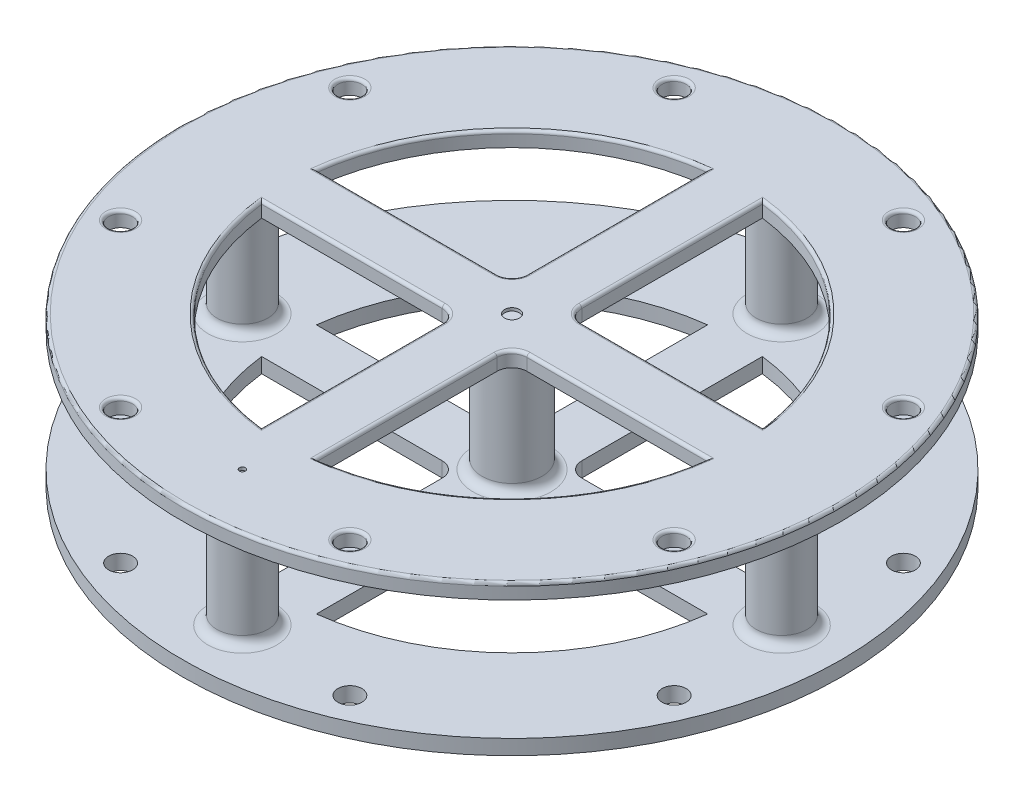
from build123d import *

# Parameters (mm, degrees)
SKETCH1_R               = 279.4
SKETCH1_R_2             = 10.16
SKETCH1_R_3             = 228.6
BOSS_EXTRUDE1_DEPTH     = 127
FILLET1_R               = 2.54
SKETCH2_W               = 558.8
SKETCH2_H               = 101.6
CUT_EXTRUDE1_DEPTH      = 416.039419845
CUT_EXTRUDE1_DEPTH_BACK = 416.039419845
SKETCH3_R               = 6.35
CUT_EXTRUDE2_DEPTH      = 6.35
SKETCH5_R               = 3.175
BOSS_EXTRUDE3_DEPTH     = 2.54
BOSS_EXTRUDE4_REACH     = 414.044
SKETCH6_R               = 25.4
SKETCH6_R_2             = 21.59
FILLET2_R               = 7.62
FILLET3_R               = 7.62
SKETCH7_R               = 6.35
SKETCH7_R_2             = 2.54
CUT_EXTRUDE3_DEPTH      = 2.54


with BuildPart() as part:
    # Sketch1 → Boss-Extrude1 (new body)
    with BuildSketch(Plane(origin=(0, 0, 0), x_dir=(1, 0, 0), z_dir=(0, 1, 0))):
        with Locations(Location((0, 0, 0), (0, 0, 270))):
            Circle(SKETCH1_R)
        with Locations(Location((234.665401258, -97.201591821, 0), (0, 0, 270))):
            Circle(SKETCH1_R_2, mode=Mode.SUBTRACT)
        with Locations(Location((97.201591821, -234.665401258, 0), (0, 0, 270))):
            Circle(SKETCH1_R_2, mode=Mode.SUBTRACT)
        with Locations(Location((97.201591821, 234.665401258, 0), (0, 0, 270))):
            Circle(SKETCH1_R_2, mode=Mode.SUBTRACT)
        with Locations(Location((234.665401258, 97.201591821, 0), (0, 0, 270))):
            Circle(SKETCH1_R_2, mode=Mode.SUBTRACT)
        with Locations(Location((-234.665401258, 97.201591821, 0), (0, 0, 270))):
            Circle(SKETCH1_R_2, mode=Mode.SUBTRACT)
        with Locations(Location((-97.201591821, 234.665401258, 0), (0, 0, 270))):
            Circle(SKETCH1_R_2, mode=Mode.SUBTRACT)
        with Locations(Location((-97.201591821, -234.665401258, 0), (0, 0, 270))):
            Circle(SKETCH1_R_2, mode=Mode.SUBTRACT)
        with Locations(Location((-234.665401258, -97.201591821, 0), (0, 0, 270))):
            Circle(SKETCH1_R_2, mode=Mode.SUBTRACT)
        Circle(SKETCH1_R_3, mode=Mode.SUBTRACT)
        Circle(SKETCH1_R_3)
        with BuildLine():
            ThreePointArc((-23.221024484, 189.07943839), (-134.703841816, 134.703841816), (-189.07943839, 23.221024484))
            Line((-189.07943839, 23.221024484), (-35.921024484, 23.221024484))
            ThreePointArc((-35.921024484, 23.221024484), (-26.940768363, 26.940768363), (-23.221024484, 35.921024484))
            Line((-23.221024484, 35.921024484), (-23.221024484, 189.07943839))
        make_face(mode=Mode.SUBTRACT)
        with BuildLine():
            ThreePointArc((189.07943839, 23.221024484), (134.703841816, 134.703841816), (23.221024484, 189.07943839))
            Line((23.221024484, 189.07943839), (23.221024484, 35.921024484))
            ThreePointArc((23.221024484, 35.921024484), (26.940768363, 26.940768363), (35.921024484, 23.221024484))
            Line((35.921024484, 23.221024484), (189.07943839, 23.221024484))
        make_face(mode=Mode.SUBTRACT)
        with BuildLine():
            ThreePointArc((-189.07943839, -23.221024484), (-134.703841816, -134.703841816), (-23.221024484, -189.07943839))
            Line((-23.221024484, -189.07943839), (-23.221024484, -35.921024484))
            ThreePointArc((-23.221024484, -35.921024484), (-26.940768363, -26.940768363), (-35.921024484, -23.221024484))
            Line((-35.921024484, -23.221024484), (-189.07943839, -23.221024484))
        make_face(mode=Mode.SUBTRACT)
        with BuildLine():
            ThreePointArc((35.921024484, -23.221024484), (26.940768363, -26.940768363), (23.221024484, -35.921024484))
            Line((23.221024484, -35.921024484), (23.221024484, -189.07943839))
            ThreePointArc((23.221024484, -189.07943839), (134.703841816, -134.703841816), (189.07943839, -23.221024484))
            Line((189.07943839, -23.221024484), (35.921024484, -23.221024484))
        make_face(mode=Mode.SUBTRACT)
    extrude(amount=BOSS_EXTRUDE1_DEPTH)

    # Fillet1
    fillet1_edges = [part.edges().sort_by_distance(p)[0] for p in [
        (-97.201591821, 127, -244.825401258),
        (-97.201591821, 127, 224.505401258),
        (-234.665401258, 127, 87.041591821),
        (0, 127, -279.4),
        (-134.703841816, 127, -134.703841816),
        (-23.221024484, 127, -112.500231437),
        (-26.940768363, 127, -26.940768363),
        (-112.500231437, 127, -23.221024484),
        (134.703841816, 127, -134.703841816),
        (112.500231437, 127, -23.221024484),
        (26.940768363, 127, -26.940768363),
        (23.221024484, 127, -112.500231437),
        (-134.703841816, 127, 134.703841816),
        (-112.500231437, 127, 23.221024484),
        (-26.940768363, 127, 26.940768363),
        (-23.221024484, 127, 112.500231437),
        (26.940768363, 127, 26.940768363),
        (112.500231437, 127, 23.221024484),
        (134.703841816, 127, 134.703841816),
        (23.221024484, 127, 112.500231437),
        (234.665401258, 127, 87.041591821),
        (97.201591821, 127, 224.505401258),
        (97.201591821, 127, -244.825401258),
        (234.665401258, 127, -107.361591821),
        (-234.665401258, 127, -107.361591821),
    ]]
    fillet(fillet1_edges, radius=FILLET1_R)

    # Sketch2 → Cut-Extrude1 (cut, two sides)
    with BuildSketch(Plane.XY) as cut_extrude1_sk:
        with Locations((0, 63.5)):
            Rectangle(SKETCH2_W, SKETCH2_H)
    extrude(amount=CUT_EXTRUDE1_DEPTH, mode=Mode.SUBTRACT)
    extrude(cut_extrude1_sk.sketch, amount=-CUT_EXTRUDE1_DEPTH_BACK, mode=Mode.SUBTRACT)


with BuildPart() as cut_extrude1_piece_1:
    # of the separate pieces the step leaves, piece 1, a body of its own (cut_extrude1_pieces)
    add(part.part.solids().sort_by_distance((0, 0, 279.4))[0])

    # Sketch3 → Cut-Extrude2 (cut)
    with BuildSketch(Plane.XZ):
        with Locations(Location((0, 0, 0), (0, 0, 270))):
            Circle(SKETCH3_R)
    extrude(amount=-CUT_EXTRUDE2_DEPTH, mode=Mode.SUBTRACT)

    # Sketch5 → Boss-Extrude3 (add)
    with BuildSketch(Plane.XZ):
        with Locations(Location((0, 190.5, 0), (0, 0, 90))):
            Circle(SKETCH5_R)
        with Locations(Location((190.5, 0, 0), (0, 0, 90))):
            Circle(SKETCH5_R)
        with Locations(Location((0, -190.5, 0), (0, 0, 90))):
            Circle(SKETCH5_R)
        with Locations(Location((-190.5, 0, 0), (0, 0, 90))):
            Circle(SKETCH5_R)
    extrude(amount=BOSS_EXTRUDE3_DEPTH)

    # Sketch6 → Boss-Extrude4 (add, up to next)
    with BuildSketch(Plane.XZ.offset(-114.3), mode=Mode.PRIVATE) as boss_extrude4_sk1:
        with Locations(Location((0, 0, 0), (0, 0, 180))):
            Circle(SKETCH6_R)
    boss_extrude4_tool1 = extrude(boss_extrude4_sk1.sketch, amount=BOSS_EXTRUDE4_REACH, mode=Mode.PRIVATE) - cut_extrude1_piece_1.part
    # Sketch6 → Boss-Extrude4 (add, up to next)
    with BuildSketch(Plane.XZ.offset(-114.3), mode=Mode.PRIVATE) as boss_extrude4_sk2:
        with Locations(Location((0, 228.6, 0), (0, 0, 180))):
            Circle(SKETCH6_R_2)
    boss_extrude4_tool2 = extrude(boss_extrude4_sk2.sketch, amount=BOSS_EXTRUDE4_REACH, mode=Mode.PRIVATE) - cut_extrude1_piece_1.part
    # Sketch6 → Boss-Extrude4 (add, up to next)
    with BuildSketch(Plane.XZ.offset(-114.3), mode=Mode.PRIVATE) as boss_extrude4_sk3:
        with Locations(Location((228.6, 0, 0), (0, 0, 180))):
            Circle(SKETCH6_R_2)
    boss_extrude4_tool3 = extrude(boss_extrude4_sk3.sketch, amount=BOSS_EXTRUDE4_REACH, mode=Mode.PRIVATE) - cut_extrude1_piece_1.part
    # Sketch6 → Boss-Extrude4 (add, up to next)
    with BuildSketch(Plane.XZ.offset(-114.3), mode=Mode.PRIVATE) as boss_extrude4_sk4:
        with Locations(Location((0, -228.6, 0), (0, 0, 180))):
            Circle(SKETCH6_R_2)
    boss_extrude4_tool4 = extrude(boss_extrude4_sk4.sketch, amount=BOSS_EXTRUDE4_REACH, mode=Mode.PRIVATE) - cut_extrude1_piece_1.part
    # Sketch6 → Boss-Extrude4 (add, up to next)
    with BuildSketch(Plane.XZ.offset(-114.3), mode=Mode.PRIVATE) as boss_extrude4_sk5:
        with Locations(Location((-228.6, 0, 0), (0, 0, 180))):
            Circle(SKETCH6_R_2)
    boss_extrude4_tool5 = extrude(boss_extrude4_sk5.sketch, amount=BOSS_EXTRUDE4_REACH, mode=Mode.PRIVATE) - cut_extrude1_piece_1.part


with BuildPart() as cut_extrude1_piece_2:
    # of the separate pieces the step leaves, piece 2, a body of its own (cut_extrude1_pieces)
    add(part.part.solids().sort_by_distance((0, 114.3, 279.4))[0])


with BuildPart() as cut_extrude1_piece_1_1:
    add(cut_extrude1_piece_1.part)

    add(cut_extrude1_piece_2.part)  # Boss-Extrude4 merges Cut-Extrude1 piece 2
    add(boss_extrude4_tool1.solids().sort_by_distance((0, 114.3, 0))[0])
    add(boss_extrude4_tool2.solids().sort_by_distance((0, 114.3, 228.6))[0])
    add(boss_extrude4_tool3.solids().sort_by_distance((228.6, 114.3, 0))[0])
    add(boss_extrude4_tool4.solids().sort_by_distance((0, 114.3, -228.6))[0])
    add(boss_extrude4_tool5.solids().sort_by_distance((-228.6, 114.3, 0))[0])

    # Fillet2
    fillet2_edges = [cut_extrude1_piece_1_1.edges().sort_by_distance(p)[0] for p in [
        (25.4, 114.3, 0),
        (25.4, 12.7, 0),
    ]]
    fillet(fillet2_edges, radius=FILLET2_R)

    # Fillet3
    fillet3_edges = [cut_extrude1_piece_1_1.edges().sort_by_distance(p)[0] for p in [
        (21.59, 12.7, 228.6),
        (21.59, 114.3, 228.6),
        (250.19, 12.7, 0),
        (250.19, 114.3, 0),
        (21.59, 12.7, -228.6),
        (21.59, 114.3, -228.6),
        (-207.01, 12.7, 0),
        (-207.01, 114.3, 0),
    ]]
    fillet(fillet3_edges, radius=FILLET3_R)

    # Sketch7 → Cut-Extrude3 (cut)
    with BuildSketch(Plane(origin=(0, 127, 0), x_dir=(1, 0, 0), z_dir=(0, 1, 0))):
        with Locations(Location((0, 0, 0), (0, 0, 90))):
            Circle(SKETCH7_R)
        with Locations(Location((0, -228.6, 0), (0, 0, 270))):
            Circle(SKETCH7_R_2)
    extrude(amount=-CUT_EXTRUDE3_DEPTH, mode=Mode.SUBTRACT)


solid = cut_extrude1_piece_1_1.part
